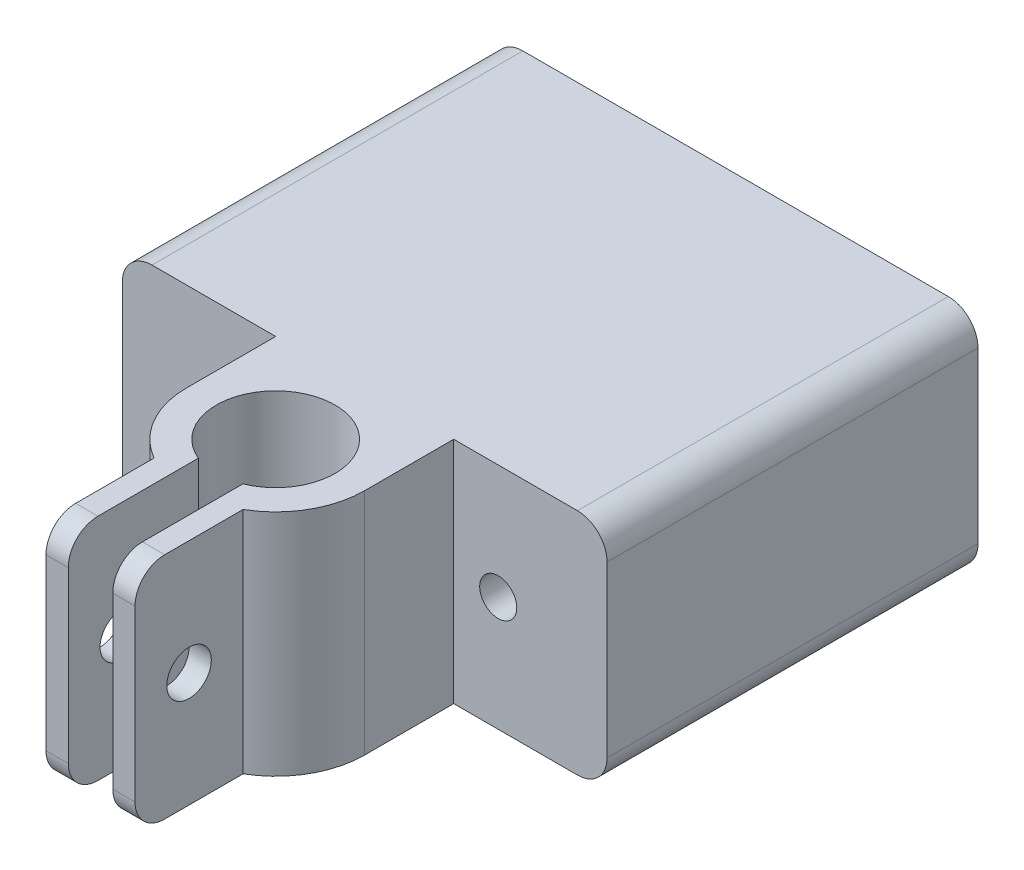
from build123d import *

# Parameters (mm, degrees)
SKETCH_1_W          = 32.677388302
SKETCH_1_H          = 15.432977872
EXTRUDE_1_DEPTH     = 25
SKETCH_2_R          = 1.25
CUT_EXTRUDE_1_DEPTH = 26
SKETCH_3_R          = 6
EXTRUDE_2_DEPTH     = 15.432978
SKETCH_4_R          = 4
CUT_EXTRUDE_2_DEPTH = 16.432978
EXTRUDE_3_DEPTH     = 15.432978
SKETCH_6_W          = 6
SKETCH_6_H          = 8.481168663
EXTRUDE_4_DEPTH     = 15.432978
SKETCH_8_W          = 3
SKETCH_8_H          = 25.378391716
CUT_EXTRUDE_5_DEPTH = 16.432978
SKETCH_9_R          = 1.5
CUT_EXTRUDE_6_DEPTH = 20.338694151
FILLET_1_R          = 2
FILLET_2_R          = 2


with BuildPart() as part:
    # 草图1 → 凸台-拉伸1 (new body)
    with BuildSketch(Plane.XY):
        with Locations((-3.726697353, 26.358574689)):
            Rectangle(SKETCH_1_W, SKETCH_1_H)
    extrude(amount=-EXTRUDE_1_DEPTH)

    # 草图2 → 切除-拉伸1 (cut, through all)
    with BuildSketch(Plane.XY):
        with Locations((-12.726697353, 26.358574689)):
            Circle(SKETCH_2_R)
        with Locations((5.273302647, 26.358574689)):
            Circle(SKETCH_2_R)
    extrude(amount=-CUT_EXTRUDE_1_DEPTH, mode=Mode.SUBTRACT)



with BuildPart() as body_2:
    # 草图3 → 凸台-拉伸2 (new body)
    with BuildSketch(Plane.XZ.offset(-18.642085753)):
        with Locations((-3.726697353, 6)):
            Circle(SKETCH_3_R)
    extrude(amount=-EXTRUDE_2_DEPTH)

    # 草图4 → 切除-拉伸2 (cut, through all)
    with BuildSketch(Plane.XZ.offset(-18.642085753)):
        with Locations((-3.726697353, 6)):
            Circle(SKETCH_4_R)
    extrude(amount=-CUT_EXTRUDE_2_DEPTH, mode=Mode.SUBTRACT)


with BuildPart() as part_1:
    add(part.part)

    add(body_2.part)  # 凸台-拉伸3 merges body 2
    # 草图5 → 凸台-拉伸3 (add)
    with BuildSketch(Plane.XZ.offset(-18.642085753)):
        Polygon((-3.726697353, 0), (-9.726697353, 6), (-9.726697353, 0), align=None)
        Polygon((2.273302647, 6), (-3.726697353, 0), (2.273302647, 0), align=None)
    extrude(amount=-EXTRUDE_3_DEPTH)

    # 草图6 → 凸台-拉伸4 (add)
    with BuildSketch(Plane.XZ.offset(-18.642085753)):
        with Locations((-3.726697353, 14.240584332)):
            Rectangle(SKETCH_6_W, SKETCH_6_H)
    extrude(amount=-EXTRUDE_4_DEPTH)

    # 草图8 → 切除-拉伸5 (cut, through all)
    with BuildSketch(Plane.XZ.offset(-18.642085753)):
        with Locations((-3.726697353, 18.689195858)):
            Rectangle(SKETCH_8_W, SKETCH_8_H)
    extrude(amount=-CUT_EXTRUDE_5_DEPTH, mode=Mode.SUBTRACT)

    # 草图9 → 切除-拉伸6 (cut, through all)
    with BuildSketch(Plane(origin=(-0.726697353, 0, 0), x_dir=(0, 0, -1), z_dir=(1, 0, 0))):
        with Locations((-14.838660543, 26.358574689)):
            Circle(SKETCH_9_R)
    extrude(amount=-CUT_EXTRUDE_6_DEPTH, mode=Mode.SUBTRACT)

    # 圆角1
    fillet_1_edges = [part_1.edges().sort_by_distance(p)[0] for p in [
        (12.611996798, 18.642085753, -12.5),
        (-20.065391504, 18.642085753, -12.5),
        (-20.065391504, 34.075063625, -12.5),
        (12.611996798, 34.075063625, -12.5),
    ]]
    fillet(fillet_1_edges, radius=FILLET_1_R)

    # 圆角2
    fillet_2_edges = [part_1.edges().sort_by_distance(p)[0] for p in [
        (-1.476697353, 18.642085753, 18.481168663),
        (-1.476697353, 34.075063753, 18.481168663),
        (-5.976697353, 34.075063753, 18.481168663),
        (-5.976697353, 18.642085753, 18.481168663),
    ]]
    fillet(fillet_2_edges, radius=FILLET_2_R)


solid = part_1.part
